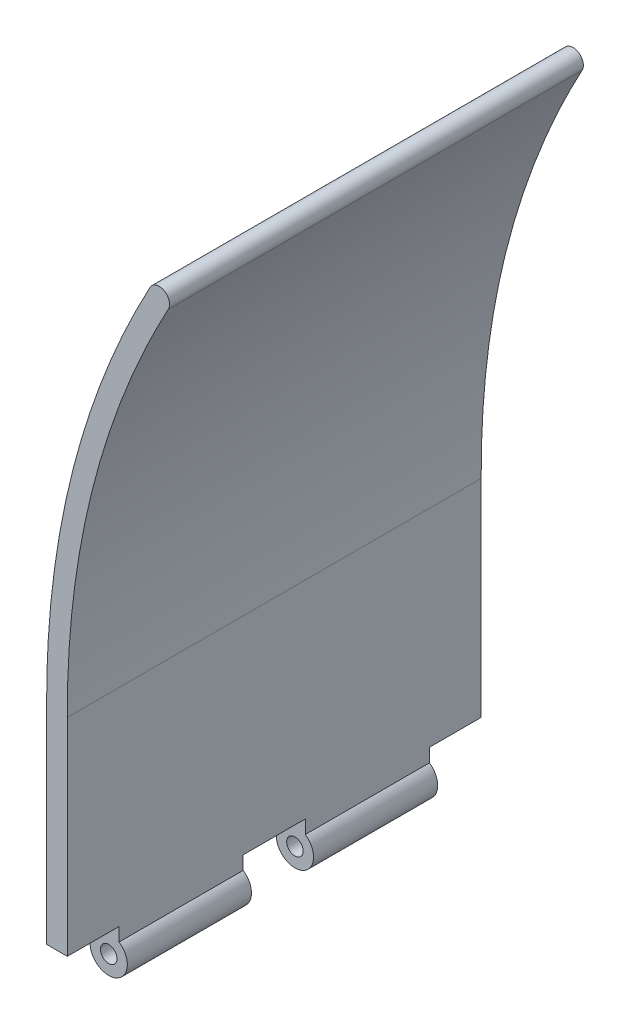
from build123d import *

# Parameters (mm, degrees)
BOSS_EXTRUDE1_DEPTH = 50
BOSS_EXTRUDE2_START = -12.5
SKETCH2_R           = 2
BOSS_EXTRUDE2_DEPTH = 30


with BuildPart() as part:
    # Sketch1 → Boss-Extrude1 (new body, symmetric)
    with BuildSketch(Plane.XY):
        with BuildLine():
            Line((0, 0), (0, 50))
            add(Edge.make_bspline(
                [(0, 50), (-0.236079675, 103.300249741), (25, 150)],
                knots=[0, 0, 0, 1, 1, 1], degree=2))
            ThreePointArc((25, 150), (28.387941146, 151.010868336), (29.398809482, 147.62292719))
            add(Edge.make_bspline(
                [(5, 50.011073049), (4.990421387, 52.173658537), (5.035623154, 56.511554686), (5.385764781, 65.083196163), (6.308823956, 75.675961605), (8.192566934, 88.173154483), (10.852002898, 100.466008633), (14.287860292, 112.557101091), (18.500659336, 124.449247631), (22.66257211, 134.200371846), (26.379067858, 141.898054896), (28.374986615, 145.728327364), (29.398809482, 147.62292719)],
                knots=[-0.000103873, -0.000103873, -0.000103873, -0.000103873, 0.062402619, 0.124909111, 0.249922095, 0.374935079, 0.499948063, 0.624961048, 0.749974032, 0.874987016, 0.937493508, 1, 1, 1, 1], degree=3))
            Line((5, 50.011073049), (5, 0))
            Line((5, 0), (0, 0))
        make_face()
    extrude(amount=BOSS_EXTRUDE1_DEPTH, both=True)

    # Sketch2 → Boss-Extrude2 (add)
    with BuildSketch(Plane.XY.offset(50).offset(BOSS_EXTRUDE2_START)):
        with BuildLine():
            Line((5, -3.258342613), (0, -3.258342613))
            ThreePointArc((0, -3.258342613), (0.378679656, -10.968626967), (7, -7))
            ThreePointArc((7, -7), (6.468626967, -4.878679656), (5, -3.258342613))
        make_face()
        with Locations((2.5, -7)):
            Circle(SKETCH2_R, mode=Mode.SUBTRACT)
        with BuildLine():
            ThreePointArc((5, -3.258342613), (2.5, -2.5), (0, -3.258342613))
            Line((0, -3.258342613), (5, -3.258342613))
        make_face()
        with BuildLine():
            Line((5, 0), (0, 0))
            Line((0, 0), (0, -3.258342613))
            ThreePointArc((0, -3.258342613), (2.5, -2.5), (5, -3.258342613))
            Line((5, -3.258342613), (5, 0))
        make_face()
    boss_extrude2 = extrude(amount=-BOSS_EXTRUDE2_DEPTH)

    # Mirror1: Boss-Extrude2 across plane
    add(boss_extrude2.mirror(Plane.XY))


solid = part.part
